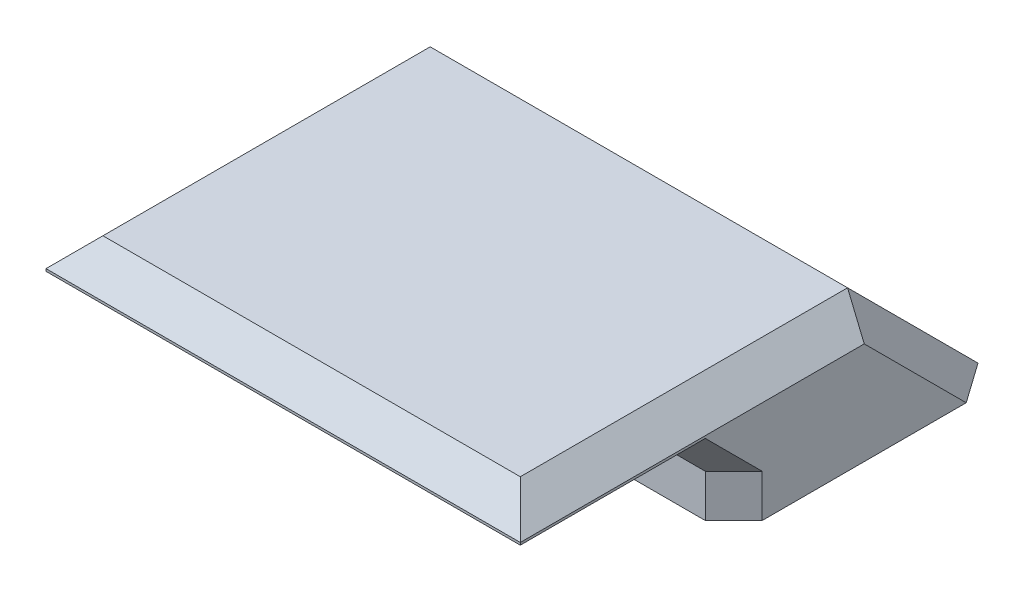
from build123d import *

# Parameters (mm, degrees)
SKETCH_1_W      = 20
SKETCH_1_H      = 6
SKETCH_1_R      = 1.4
EXTRUDE_1_DEPTH = 3
SKETCH_2_W      = 20
SKETCH_2_H      = 15
EXTRUDE_2_DEPTH = 2.5
EXTRUDE_3_DEPTH = 20
CHAMFER_1_SIZE  = 1.2


with BuildPart() as part:
    # 草图1 → 凸台-拉伸1 (new body)
    with BuildSketch(Plane(origin=(0, 0, 0), x_dir=(1, 0, 0), z_dir=(0, 1, 0))):
        Rectangle(SKETCH_1_W, SKETCH_1_H)
        with Locations((-7, 0)):
            Circle(SKETCH_1_R, mode=Mode.SUBTRACT)
        with Locations((7, 0)):
            Circle(SKETCH_1_R, mode=Mode.SUBTRACT)
    extrude(amount=EXTRUDE_1_DEPTH)

    # 草图2 → 凸台-拉伸2 (add)
    with BuildSketch(Plane(origin=(0, 3, 0), x_dir=(1, 0, 0), z_dir=(0, 1, 0))):
        with Locations((0, -4.5)):
            Rectangle(SKETCH_2_W, SKETCH_2_H)
    extrude(amount=EXTRUDE_2_DEPTH)

    # 草图3 → 凸台-拉伸3 (add)
    with BuildSketch(Plane.ZY.offset(10)):
        Polygon((-3, 5.5), (-8.5, 0), (-3, 0), align=None)
    extrude(amount=-EXTRUDE_3_DEPTH)

    # 倒角1
    chamfer_1_edges = [part.edges().sort_by_distance(p)[0] for p in [
        (0, 3, 3),
        (-10, 3, 7.5),
        (0, 3, 12),
        (10, 3, 7.5),
        (-10, 5.5, 4.5),
        (0, 5.5, 12),
        (10, 5.5, 4.5),
        (10, 2.75, -5.75),
        (-10, 2.75, -5.75),
        (10, 1.5, 3),
        (-10, 1.5, 3),
    ]]
    chamfer(chamfer_1_edges, length=CHAMFER_1_SIZE)


solid = part.part
